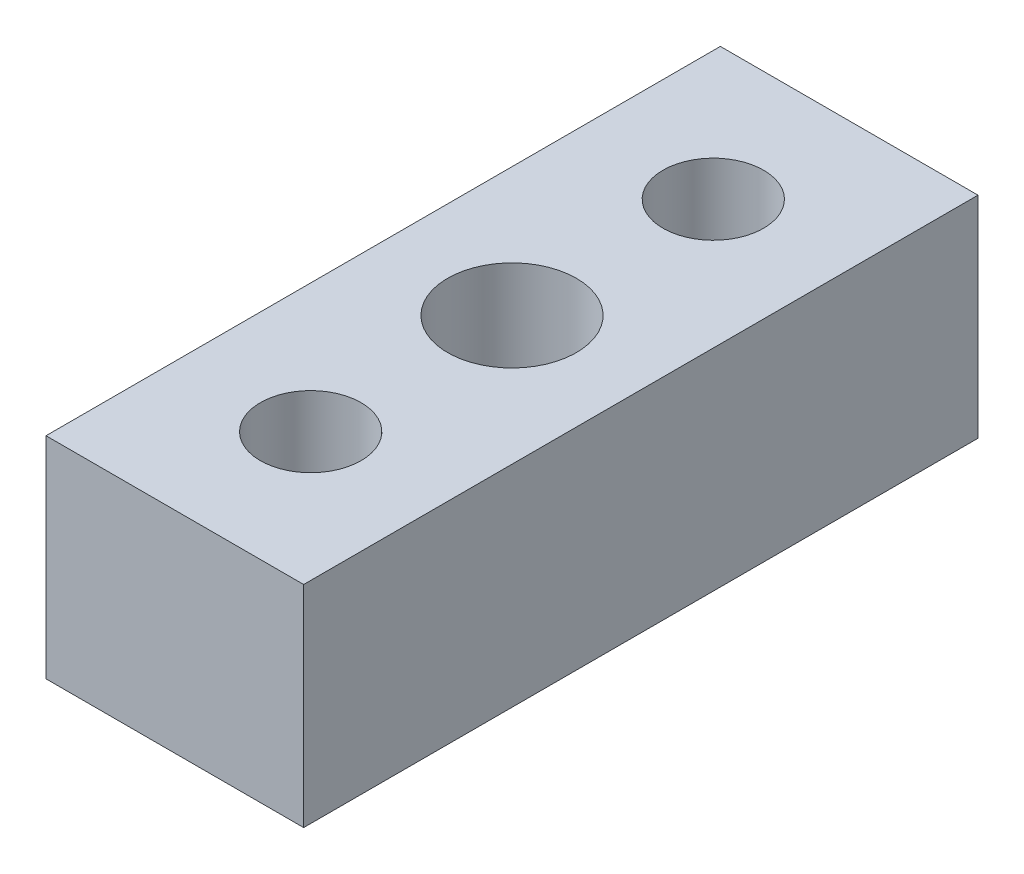
from build123d import *

# Parameters (mm, degrees)
SKETCH1_W             = 4.084
SKETCH1_H             = 6.24
EXTRUDE1_DEPTH        = 7
SKETCH6_W             = 6.834
SKETCH6_H             = 16.75
EXTRUDE2_DEPTH        = 5.23
F_4_CLEARANCE_HOLE1_D = 3.2
SKETCH3_R             = 1.25
CUT_EXTRUDE1_DEPTH    = 7.24
SKETCH7_W             = 0.217
SKETCH7_H             = 16.75
EXTRUDE3_DEPTH        = 6.23


with BuildPart() as part:
    # Sketch1 → Extrude1 (new body, symmetric)
    with BuildSketch(Plane.XY):
        Rectangle(SKETCH1_W, SKETCH1_H)
    extrude(amount=EXTRUDE1_DEPTH, both=True)

    # Sketch6 → Extrude2 (add)
    with BuildSketch(Plane(origin=(0, 3.12, 0), x_dir=(1, 0, 0), z_dir=(0, 1, 0))):
        Rectangle(SKETCH6_W, SKETCH6_H)
    extrude(amount=-EXTRUDE2_DEPTH)

    # 4 Clearance Hole1 (through all)
    with Locations(Plane(origin=(0.396685659, -3.12, 2.776888518), x_dir=(1, 0, 0), z_dir=(0, -1, 0))):
        with Locations((-0.396685659, -2.776888518)):
            Hole(F_4_CLEARANCE_HOLE1_D / 2)

    # Sketch3 → Cut-Extrude1 (cut, through all)
    with BuildSketch(Plane(origin=(0, -3.12, 0), x_dir=(-1, 0, 0), z_dir=(0, -1, 0))):
        with Locations(Location((0, -5, 0), (0, 0, 180))):  # turned: the seam where the file's is
            Circle(SKETCH3_R)
        with Locations((0, 5)):
            Circle(SKETCH3_R)
    extrude(amount=-CUT_EXTRUDE1_DEPTH, mode=Mode.SUBTRACT)

    # Sketch7 → Extrude3 (cut, through all)
    with BuildSketch(Plane.XZ.offset(2.11)):
        with Locations((3.3085, 0)):
            Rectangle(SKETCH7_W, SKETCH7_H)
    extrude3 = extrude(amount=-EXTRUDE3_DEPTH, mode=Mode.SUBTRACT)

    # Mirror1: Extrude3 across plane
    add(extrude3.mirror(Plane(origin=(0, 0, 0), x_dir=(0, 0, 1), z_dir=(1, 0, 0))), mode=Mode.SUBTRACT)


solid = part.part
